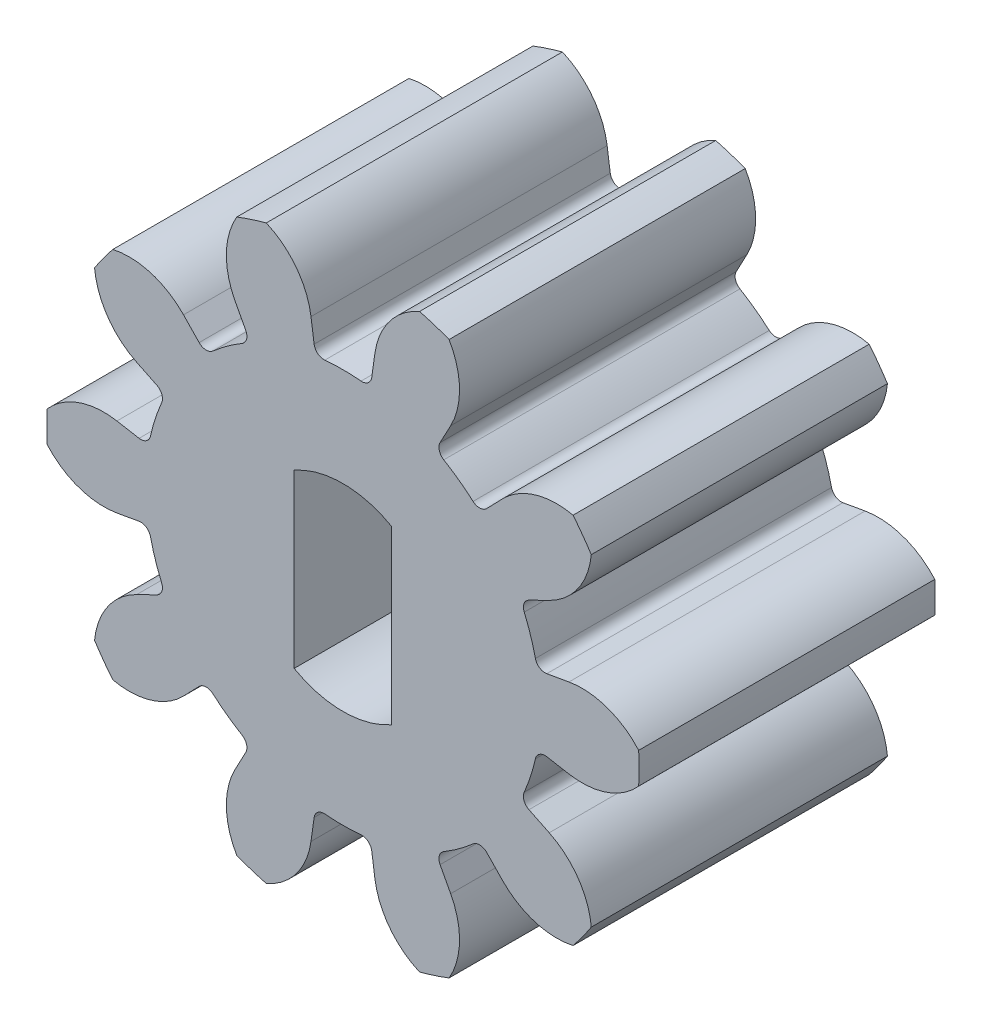
from build123d import *

# Parameters (mm, degrees)
BOSS_EXTRUDE1_DEPTH      = 6
FILLET3_R                = 0.2
FILLET4_R                = 0.2
CIRPATTERN1_COUNT        = 10
FILLET3_OF_CIRPATTERN1_R = 0.2
FILLET4_OF_CIRPATTERN1_R = 0.2
CUT_EXTRUDE1_DEPTH       = 7
CUT_EXTRUDE1_DEPTH_BACK  = 6


with BuildPart() as part:
    # Sketch1 → Boss-Extrude1 (new body)
    with BuildSketch(Plane.XY):
        with BuildLine():
            Line((0, 0), (3.80266937, -1.235562177))
            ThreePointArc((3.80266937, -1.235562177), (3.87959472, -0.967291603), (3.937619073, -0.694308482))
            Line((3.937619073, -0.694308482), (4.579356052, -0.807464026))
            ThreePointArc((4.579356052, -0.807464026), (5.349965783, -0.745072725), (5.991777209, -0.314015737))
            ThreePointArc((5.991777209, -0.314015737), (6, 0), (5.991777209, 0.314015737))
            ThreePointArc((5.991777209, 0.314015737), (5.349965783, 0.745072725), (4.579356052, 0.807464026))
            Line((4.579356052, 0.807464026), (3.937619073, 0.694308482))
            ThreePointArc((3.937619073, 0.694308482), (3.87959472, 0.967291603), (3.80266937, 1.235562177))
            Line((3.80266937, 1.235562177), (0, 0))
        make_face()
    boss_extrude1 = extrude(amount=BOSS_EXTRUDE1_DEPTH)

    # Fillet3
    fillet3_edges = [part.edges().sort_by_distance(p)[0] for p in [
        (3.937619073, 0.694308482, 3),
    ]]
    fillet(fillet3_edges, radius=FILLET3_R)

    # Fillet4
    fillet4_edges = [part.edges().sort_by_distance(p)[0] for p in [
        (3.937619073, -0.694308482, 3),
    ]]
    fillet(fillet4_edges, radius=FILLET4_R)

    # CirPattern1: Boss-Extrude1 ×10 about axis
    cirpattern1_axis = Axis((0, 0, 0), (0, 0, 1))
    for i in range(1, CIRPATTERN1_COUNT):
        add(boss_extrude1.rotate(cirpattern1_axis, i * 360 / CIRPATTERN1_COUNT))

    # Fillet3 of CirPattern1
    fillet3_of_cirpattern1_edges = [part.edges().sort_by_distance(p)[0] for p in [
        (2.777496461, 2.876181782, 3),
        (0.556464605, 3.959451399, 3),
        (-1.877117817, 3.530345158, 3),
        (-3.593705034, 1.752767059, 3),
        (-3.937619073, -0.694308482, 3),
        (-2.777496461, -2.876181782, 3),
        (-0.556464605, -3.959451399, 3),
        (1.877117817, -3.530345158, 3),
        (3.593705034, -1.752767059, 3),
    ]]
    fillet(fillet3_of_cirpattern1_edges, radius=FILLET3_OF_CIRPATTERN1_R)

    # Fillet4 of CirPattern1
    fillet4_of_cirpattern1_edges = [part.edges().sort_by_distance(p)[0] for p in [
        (3.593705034, 1.752767059, 3),
        (1.877117817, 3.530345158, 3),
        (-0.556464605, 3.959451399, 3),
        (-2.777496461, 2.876181782, 3),
        (-3.937619073, 0.694308482, 3),
        (-3.593705034, -1.752767059, 3),
        (-1.877117817, -3.530345158, 3),
        (0.556464605, -3.959451399, 3),
        (2.777496461, -2.876181782, 3),
    ]]
    fillet(fillet4_of_cirpattern1_edges, radius=FILLET4_OF_CIRPATTERN1_R)

    # Sketch2 → Cut-Extrude1 (cut, two sides)
    with BuildSketch(Plane.XY) as cut_extrude1_sk:
        with BuildLine():
            Line((-0.988569227, 1.739), (-0.988569227, -1.739))
            ThreePointArc((-0.988569227, -1.739), (0, -2.000347499), (0.988569227, -1.739))
            Line((0.988569227, -1.739), (0.988569227, 1.739))
            ThreePointArc((0.988569227, 1.739), (0, 2.000347499), (-0.988569227, 1.739))
        make_face()
    extrude(amount=CUT_EXTRUDE1_DEPTH, mode=Mode.SUBTRACT)
    extrude(cut_extrude1_sk.sketch, amount=-CUT_EXTRUDE1_DEPTH_BACK, mode=Mode.SUBTRACT)


solid = part.part
